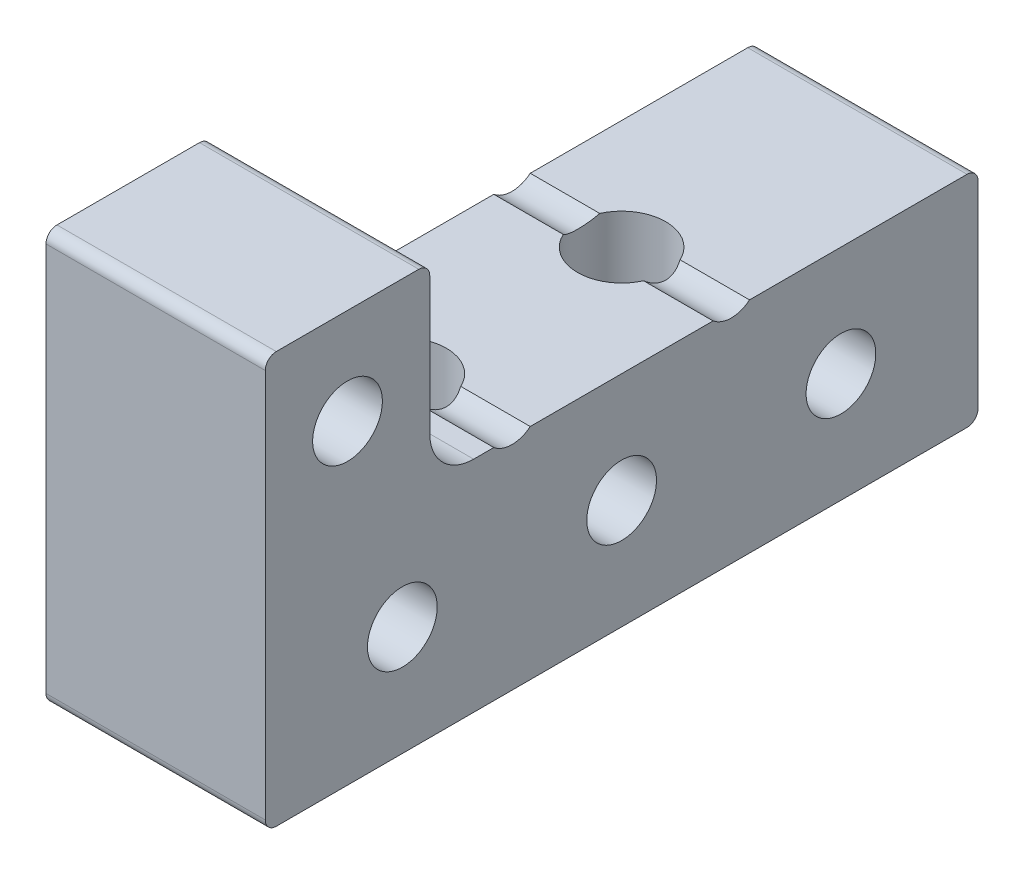
from build123d import *

# Parameters (mm, degrees)
SKETCH12_W           = 12.7
SKETCH12_H           = 41.275
SKETCH12_R           = 2.5527
BOSS_EXTRUDE5_DEPTH  = 12.7
SKETCH13_R           = 2.0193
CUT_EXTRUDE3_DEPTH   = 13.7
SKETCH107_W          = 9.525
SKETCH107_H          = 11.1125
SKETCH107_R          = 2.0193
BOSS_EXTRUDE34_DEPTH = 12.7
SKETCH112_R          = 1.651
CUT_EXTRUDE58_DEPTH  = 13.7
FILLET43_R           = 2.54
FILLET44_R           = 0.635


with BuildPart() as part:
    # Sketch12 → Boss-Extrude5 (new body)
    with BuildSketch(Plane(origin=(0, 19.05, 0), x_dir=(1, 0, 0), z_dir=(0, 1, 0))):
        with Locations((-98.425, -57.012186106)):
            Rectangle(SKETCH12_W, SKETCH12_H)
        with Locations((-98.425, -63.362186106)):
            Circle(SKETCH12_R, mode=Mode.SUBTRACT)
        with Locations((-98.425, -50.662186106)):
            Circle(SKETCH12_R, mode=Mode.SUBTRACT)
    extrude(amount=-BOSS_EXTRUDE5_DEPTH)

    # Sketch13 → Cut-Extrude3 (cut, through all)
    with BuildSketch(Plane.ZY.offset(104.775)):
        with Locations((44.312186106, 12.7)):
            Circle(SKETCH13_R)
        with Locations((57.012186106, 12.7)):
            Circle(SKETCH13_R)
        with Locations((69.712186106, 12.7)):
            Circle(SKETCH13_R)
    extrude(amount=-CUT_EXTRUDE3_DEPTH, mode=Mode.SUBTRACT)

    # Sketch107 → Boss-Extrude34 (add, through all)
    with BuildSketch(Plane(origin=(-92.075, 0, 0), x_dir=(0, 0, -1), z_dir=(1, 0, 0))):
        with Locations((-72.887186106, 24.60625)):
            Rectangle(SKETCH107_W, SKETCH107_H)
        with Locations((-72.887186106, 24.60625)):
            Circle(SKETCH107_R, mode=Mode.SUBTRACT)
    extrude(amount=-BOSS_EXTRUDE34_DEPTH)

    # Sketch112 → Cut-Extrude58 (cut, through all)
    with BuildSketch(Plane.ZY.offset(104.775)):
        with Locations((50.662186106, 20.32)):
            Circle(SKETCH112_R)
        with Locations((63.362186106, 20.32)):
            Circle(SKETCH112_R)
    extrude(amount=-CUT_EXTRUDE58_DEPTH, mode=Mode.SUBTRACT)

    # Fillet43
    fillet43_edges = [part.edges().sort_by_distance(p)[0] for p in [
        (-98.425, 19.05, 68.124686106),
    ]]
    fillet(fillet43_edges, radius=FILLET43_R)

    # Fillet44
    fillet44_edges = [part.edges().sort_by_distance(p)[0] for p in [
        (-98.425, 6.35, 36.374686106),
        (-98.425, 30.1625, 77.649686106),
        (-98.425, 30.1625, 68.124686106),
        (-98.425, 6.35, 77.649686106),
        (-98.425, 19.05, 36.374686106),
    ]]
    fillet(fillet44_edges, radius=FILLET44_R)


solid = part.part
